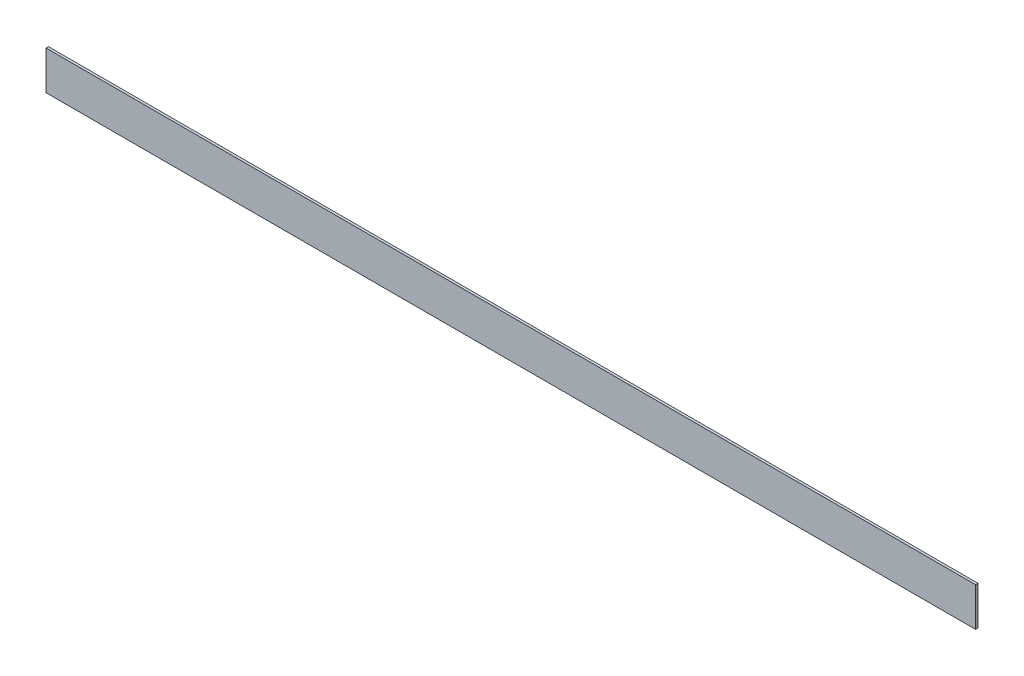
from build123d import *

# Parameters (mm, degrees)
SKETCH1_W           = 609.6
SKETCH1_H           = 25.4
BOSS_EXTRUDE1_DEPTH = 1.5875


with BuildPart() as part:
    # Sketch1 → Boss-Extrude1 (new body)
    with BuildSketch(Plane.XY):
        Rectangle(SKETCH1_W, SKETCH1_H)
    extrude(amount=BOSS_EXTRUDE1_DEPTH)


solid = part.part
